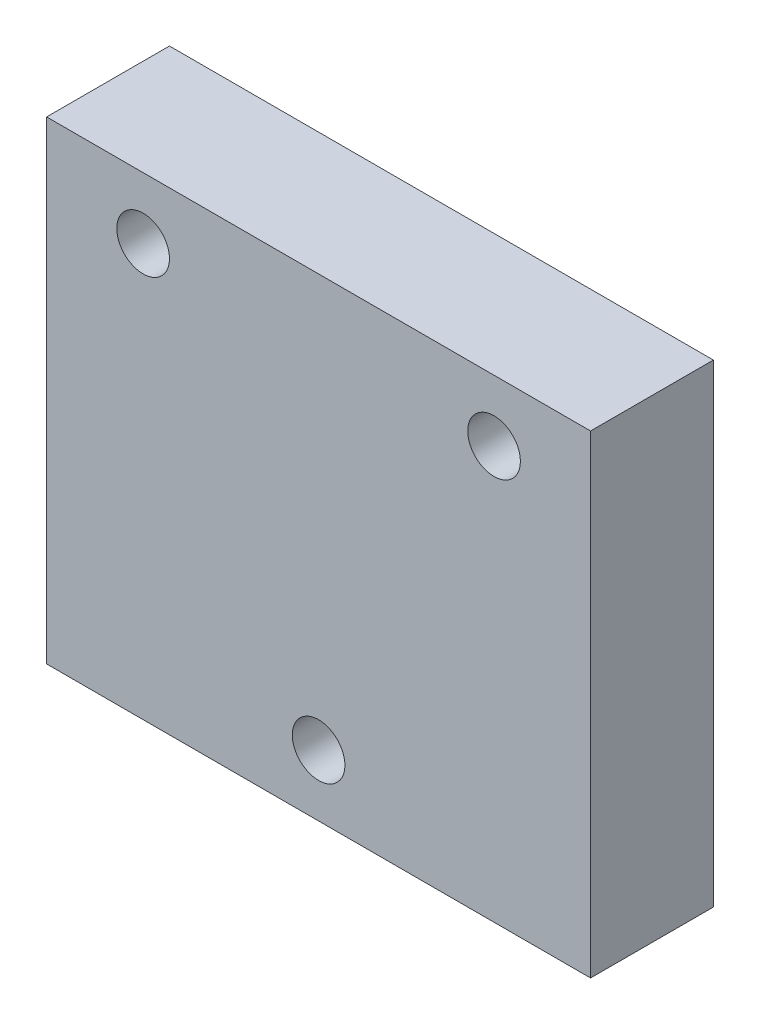
from build123d import *

# Parameters (mm, degrees)
SKETCH_1_W          = 31
SKETCH_1_H          = 27
EXTRUDE_1_DEPTH     = 7
SKETCH_2_R          = 1.5
CUT_EXTRUDE_1_DEPTH = 7


with BuildPart() as part:
    # 草图1 → 凸台-拉伸1 (new body)
    with BuildSketch(Plane.XY):
        Rectangle(SKETCH_1_W, SKETCH_1_H)
    extrude(amount=EXTRUDE_1_DEPTH)

    # 草图2 → 切除-拉伸1 (cut)
    with BuildSketch(Plane.XY.offset(7)):
        with Locations((-10, 10)):
            Circle(SKETCH_2_R)
        with Locations((10, 10)):
            Circle(SKETCH_2_R)
        with Locations((0, -10)):
            Circle(SKETCH_2_R)
    extrude(amount=-CUT_EXTRUDE_1_DEPTH, mode=Mode.SUBTRACT)


solid = part.part
